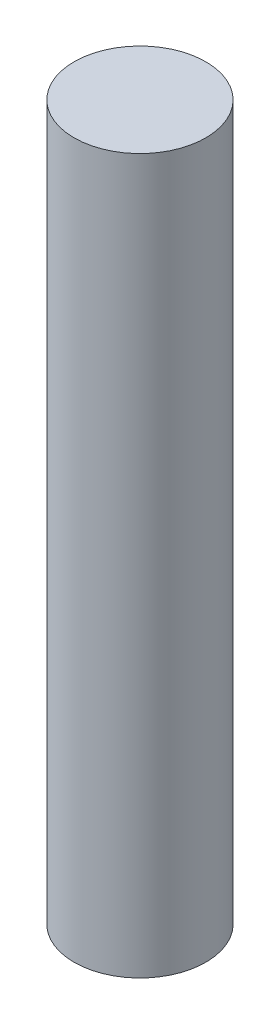
from build123d import *

# Parameters (mm, degrees)
SKETCH1_R           = 1.925
BOSS_EXTRUDE1_DEPTH = 20.86


with BuildPart() as part:
    # Sketch1 → Boss-Extrude1 (new body)
    with BuildSketch(Plane(origin=(0, 0, 0), x_dir=(1, 0, 0), z_dir=(0, 1, 0))):
        with Locations((0, 45.445)):
            Circle(SKETCH1_R)
    extrude(amount=BOSS_EXTRUDE1_DEPTH)


solid = part.part
